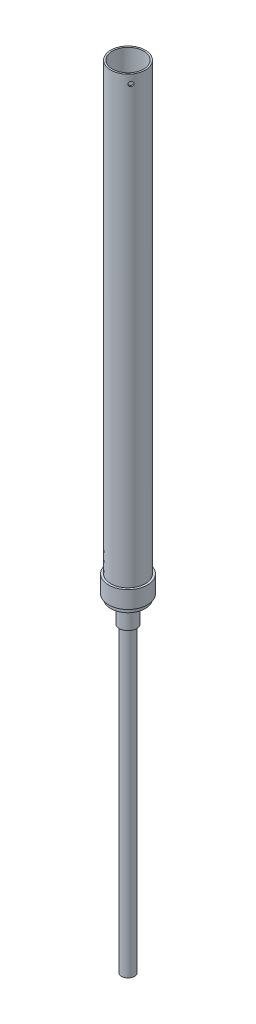
from build123d import *

# Parameters (mm, degrees)
SKETCH1_R                    = 25.4
SKETCH1_R_2                  = 23.01875
BOSS_EXTRUDE1_DEPTH          = 679.45
SKETCH2_R                    = 28.575
SKETCH2_R_2                  = 25.4
BOSS_EXTRUDE2_DEPTH          = 25.4
SKETCH4_R                    = 1.89865
CUT_EXTRUDE1_DEPTH           = 683.618175501
SKETCH5_R                    = 25.4
BOSS_EXTRUDE4_DEPTH          = 6.35
SKETCH6_R                    = 12.7
BOSS_EXTRUDE5_DEPTH          = 31.75
SKETCH7_R                    = 9.525
BOSS_EXTRUDE6_DEPTH          = 444.5
F_1_4_CLEARANCE_HOLE1_REACH  = 684.618
F_1_4_CLEARANCE_HOLE1_BORE_R = 3.3782


with BuildPart() as part:
    # Sketch1 → Boss-Extrude1 (new body)
    with BuildSketch(Plane(origin=(0, 0, 0), x_dir=(1, 0, 0), z_dir=(0, 1, 0))):
        with Locations(Location((0, 0, 0), (0, 0, 270))):
            Circle(SKETCH1_R)
        with Locations(Location((0, 0, 0), (0, 0, 270))):
            Circle(SKETCH1_R_2, mode=Mode.SUBTRACT)
    extrude(amount=BOSS_EXTRUDE1_DEPTH)

    # Sketch2 → Boss-Extrude2 (add)
    with BuildSketch(Plane(origin=(0, 0, 0), x_dir=(-1, 0, 0), z_dir=(0, -1, 0))):
        with Locations(Location((0, 0, 0), (0, 0, 90))):
            Circle(SKETCH2_R)
        with Locations(Location((0, 0, 0), (0, 0, 90))):
            Circle(SKETCH2_R_2, mode=Mode.SUBTRACT)
    extrude(amount=-BOSS_EXTRUDE2_DEPTH)

    # Sketch4 → Cut-Extrude1 (cut, through all)
    with BuildSketch(Plane(origin=(15.595341272, 0, -20.048574278), x_dir=(-0.7893139479687464, 0, -0.6139898138747834), z_dir=(0.6139898138747834, 0, -0.7893139479687464))):
        with Locations((0, 55.5625)):
            Circle(SKETCH4_R)
        with Locations((0, 42.8625)):
            Circle(SKETCH4_R)
        with Locations((0, 30.1625)):
            Circle(SKETCH4_R)
    extrude(amount=-CUT_EXTRUDE1_DEPTH, mode=Mode.SUBTRACT)

    # Sketch5 → Boss-Extrude4 (add)
    with BuildSketch(Plane.XZ):
        with Locations(Location((0, 0, 0), (0, 0, 270))):
            Circle(SKETCH5_R)
    extrude(amount=BOSS_EXTRUDE4_DEPTH)

    # Sketch6 → Boss-Extrude5 (add)
    with BuildSketch(Plane.XZ.offset(6.35)):
        with Locations(Location((0, 0, 0), (0, 0, 270))):
            Circle(SKETCH6_R)
    extrude(amount=BOSS_EXTRUDE5_DEPTH)

    # Sketch7 → Boss-Extrude6 (add)
    with BuildSketch(Plane.XZ.offset(38.1)):
        with Locations(Location((0, 0, 0), (0, 0, 270))):
            Circle(SKETCH7_R)
    extrude(amount=BOSS_EXTRUDE6_DEPTH)

    # 1/4 Clearance Hole1 bore → 1/4 Clearance Hole1 (cut, up to next)
    with BuildSketch(Plane(origin=(20.048574278, 0, 15.595341272), x_dir=(0.6139898138747835, 0, -0.7893139479687464), z_dir=(0.7893139479687464, 0, 0.6139898138747835)), mode=Mode.PRIVATE) as f_1_4_clearance_hole1_sk1:
        with Locations((0, 666.75)):
            Circle(F_1_4_CLEARANCE_HOLE1_BORE_R)
    f_1_4_clearance_hole1_tool1 = extrude(f_1_4_clearance_hole1_sk1.sketch, amount=-F_1_4_CLEARANCE_HOLE1_REACH, mode=Mode.PRIVATE) & part.part
    add(f_1_4_clearance_hole1_tool1.solids().sort_by_distance((20.048574, 666.75, 15.595341))[0], mode=Mode.SUBTRACT)


solid = part.part
